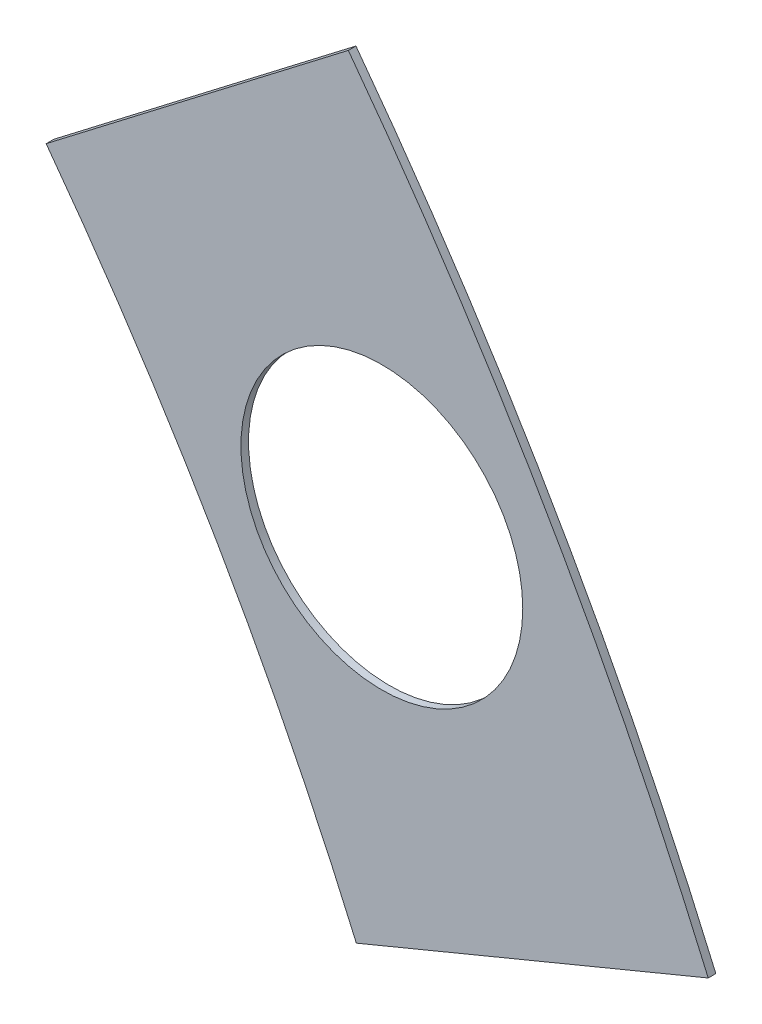
from build123d import *

# Parameters (mm, degrees)
BOSS_EXTRUDE1_DEPTH = 0.254
SKETCH2_R           = 4.699
CUT_EXTRUDE1_DEPTH  = 1.254
SKETCH3_W           = 2.54
SKETCH3_H           = 0.635
CUT_EXTRUDE2_DEPTH  = 1.254
SKETCH5_OUTSIDE_W   = 121.447
SKETCH5_OUTSIDE_H   = 109.618
CUT_EXTRUDE5_DEPTH  = 1.254


with BuildPart() as part:
    # Sketch1 → Boss-Extrude1 (new body)
    with BuildSketch(Plane.XY):
        with BuildLine():
            Line((67.21146711, 76.191723231), (8.696654013, 17.676910134))
            Line((8.696654013, 17.676910134), (7.228954972, 14.133571205))
            ThreePointArc((7.228954972, 14.133571205), (14.666587579, 6.075099489), (15.105587123, -4.88230096))
            Line((15.105587123, -4.88230096), (18.648926052, -6.35))
            Line((18.648926052, -6.35), (101.401368334, -6.35))
            ThreePointArc((101.401368334, -6.35), (93.866160503, 38.880636728), (67.21146711, 76.191723231))
        make_face()
        with BuildLine():
            Line((88.672924278, 6.35), (27.86051193, 6.35))
            ThreePointArc((27.86051193, 6.35), (26.399857642, 10.93517908), (24.190484974, 15.210228852))
            Line((24.190484974, 15.210228852), (67.191354125, 58.211098004))
            ThreePointArc((67.191354125, 58.211098004), (82.13289044, 34.020557137), (88.672924278, 6.35))
        make_face(mode=Mode.SUBTRACT)
    extrude(amount=BOSS_EXTRUDE1_DEPTH)

    # Sketch2 → Cut-Extrude1 (cut, through all)
    with BuildSketch(Plane.XY.offset(0.254)):
        with Locations((22.225, 0)):
            Circle(SKETCH2_R)
        with Locations((36.195, 0)):
            Circle(SKETCH2_R)
        with Locations((61.722, 0)):
            Circle(SKETCH2_R)
        with Locations((75.692, 0)):
            Circle(SKETCH2_R)
        with Locations((95.25, 0)):
            Circle(SKETCH2_R)
        with Locations((15.715448212, 15.715448212)):
            Circle(SKETCH2_R)
        with Locations((25.593729945, 25.593729945)):
            Circle(SKETCH2_R)
        with Locations((43.644044748, 43.644044748)):
            Circle(SKETCH2_R)
        with Locations((53.522326482, 53.522326482)):
            Circle(SKETCH2_R)
        with Locations((92.004434954, 24.652514046)):
            Circle(SKETCH2_R)
        with Locations((82.48891971, 47.625)):
            Circle(SKETCH2_R)
        with Locations((67.351920908, 67.351920908)):
            Circle(SKETCH2_R)
    extrude(amount=-CUT_EXTRUDE1_DEPTH, mode=Mode.SUBTRACT)

    # Sketch3 → Cut-Extrude2 (cut, through all)
    with BuildSketch(Plane.XY.offset(0.254)):
        Polygon((15.266435406, 24.246691527), (17.06248663, 26.042742751), (17.511499436, 25.593729945), (15.715448212, 23.797678721), align=None)
        Polygon((44.991083167, 53.971339288), (43.195031942, 52.175288063), (43.644044748, 51.726275257), (45.440095973, 53.522326482), align=None)
        with Locations((29.21, -6.0325)):
            Rectangle(SKETCH3_W, SKETCH3_H)
        with Locations((68.707, -6.0325)):
            Rectangle(SKETCH3_W, SKETCH3_H)
        Polygon((29.230733674, 38.210989795), (31.026784898, 40.007041019), (31.475797704, 39.558028213), (29.67974648, 37.761976989), align=None)
        Polygon((56.845021246, 65.825277367), (55.048970022, 64.029226143), (55.497982828, 63.580213337), (57.294034052, 65.376264561), align=None)
        with Locations((48.9585, -6.0325)):
            Rectangle(SKETCH3_W, SKETCH3_H)
        with Locations((85.471, -6.0325)):
            Rectangle(SKETCH3_W, SKETCH3_H)
        Polygon((99.935462164, 14.437711971), (100.266998693, 11.919442024), (101.526133667, 12.085210288), (101.194597138, 14.603480236), align=None)
        Polygon((93.765504959, 37.464305742), (94.938831965, 37.950313702), (93.966816047, 40.296967714), (92.793489041, 39.810959755), align=None)
        Polygon((79.327792988, 62.471156422), (80.874047017, 60.456038938), (81.88160576, 61.229165953), (80.33535173, 63.244283437), align=None)
        Polygon((13.593916116, 7.005422516), (14.565932035, 4.658768503), (15.739259041, 5.144776462), (14.767243123, 7.491430475), align=None)
    extrude(amount=-CUT_EXTRUDE2_DEPTH, mode=Mode.SUBTRACT)

    # Sketch5 outside → Cut-Extrude5 (cut, through all)
    with BuildSketch(Plane.XY.offset(0.254)):
        with Locations((54.4145, 34.921)):
            Rectangle(SKETCH5_OUTSIDE_W, SKETCH5_OUTSIDE_H)
        with BuildLine():
            Line((70.287378691, 52.332602618), (82.379165395, 61.610956889))
            ThreePointArc((82.379165395, 61.610956889), (89.088033287, 51.435), (94.546236515, 40.53697153))
            Line((94.546236515, 40.53697153), (80.465052659, 34.704354203))
            ThreePointArc((80.465052659, 34.704354203), (75.889806134, 43.815), (70.287378691, 52.332602618))
        make_face(mode=Mode.SUBTRACT)
    extrude(amount=-CUT_EXTRUDE5_DEPTH, mode=Mode.SUBTRACT)


solid = part.part
